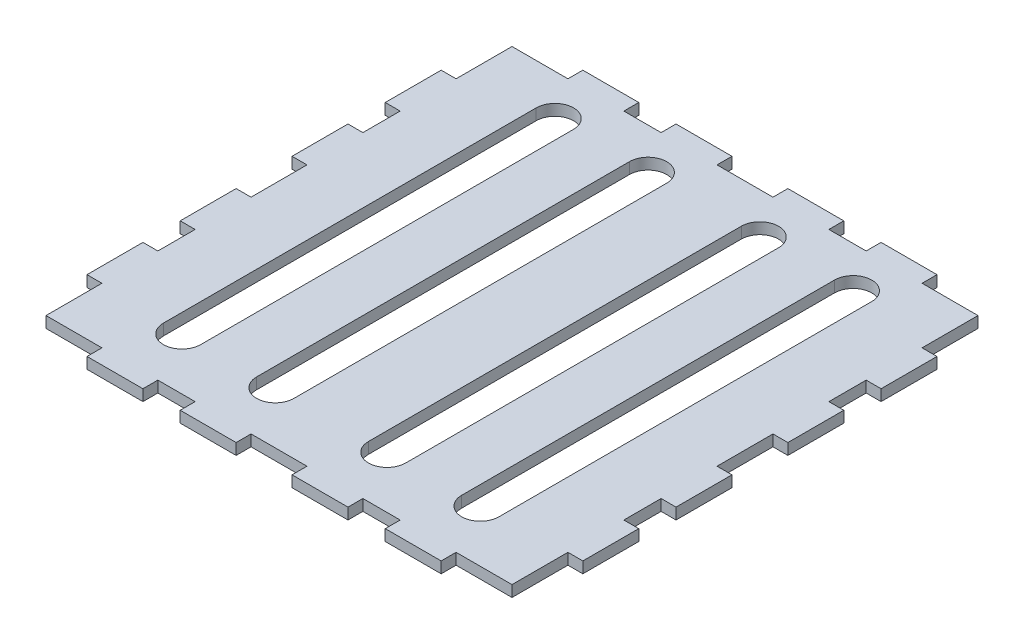
from build123d import *

# Parameters (mm, degrees)
BOSS_EXTRUDE1_DEPTH = 3


with BuildPart() as part:
    # Sketch1 → Boss-Extrude1 (new body)
    with BuildSketch(Plane(origin=(0, 0, 0), x_dir=(1, 0, 0), z_dir=(0, 1, 0))):
        Polygon((-66.5, 46), (-66.5, 31), (-62.5, 31), (-62.5, 21), (-66.5, 21), (-66.5, 6), (-62.5, 6), (-62.5, -9), (-66.5, -9), (-66.5, -24), (-62.5, -24), (-62.5, -34), (-66.5, -34), (-66.5, -49), (-62.5, -49), (-62.5, -59), (-62.5, -64), (-57.5, -64), (-47.5, -64), (-47.5, -68), (-32.5, -68), (-32.5, -64), (-22.5, -64), (-22.5, -68), (-7.5, -68), (-7.5, -64), (7.5, -64), (7.5, -68), (22.5, -68), (22.5, -64), (32.5, -64), (32.5, -68), (47.5, -68), (47.5, -64), (57.5, -64), (62.5, -64), (62.5, -59), (62.5, -49), (66.5, -49), (66.5, -34), (62.5, -34), (62.5, -24), (66.5, -24), (66.5, -9), (62.5, -9), (62.5, 6), (66.5, 6), (66.5, 21), (62.5, 21), (62.5, 31), (66.5, 31), (66.5, 46), (62.5, 46), (62.5, 56), (62.5, 61), (57.5, 61), (47.5, 61), (47.5, 65), (32.5, 65), (32.5, 61), (22.5, 61), (22.5, 65), (7.5, 65), (7.5, 61), (-7.5, 61), (-7.5, 65), (-22.5, 65), (-22.5, 61), (-32.5, 61), (-32.5, 65), (-47.5, 65), (-47.5, 61), (-57.5, 61), (-62.5, 61), (-62.5, 56), (-62.5, 46), align=None)
        with BuildLine():
            Line((-35, 50), (-35, -50))
            ThreePointArc((-35, -50), (-40, -55), (-45, -50))
            Line((-45, -50), (-45, 50))
            ThreePointArc((-45, 50), (-40, 55), (-35, 50))
        make_face(mode=Mode.SUBTRACT)
        with BuildLine():
            Line((-10, 50), (-10, -50))
            ThreePointArc((-10, -50), (-15, -55), (-20, -50))
            Line((-20, -50), (-20, 50))
            ThreePointArc((-20, 50), (-15, 55), (-10, 50))
        make_face(mode=Mode.SUBTRACT)
        with BuildLine():
            Line((10, 50), (10, -50))
            ThreePointArc((10, -50), (15, -55), (20, -50))
            Line((20, -50), (20, 50))
            ThreePointArc((20, 50), (15, 55), (10, 50))
        make_face(mode=Mode.SUBTRACT)
        with BuildLine():
            Line((35, 50), (35, -50))
            ThreePointArc((35, -50), (40, -55), (45, -50))
            Line((45, -50), (45, 50))
            ThreePointArc((45, 50), (40, 55), (35, 50))
        make_face(mode=Mode.SUBTRACT)
    extrude(amount=BOSS_EXTRUDE1_DEPTH)


solid = part.part
